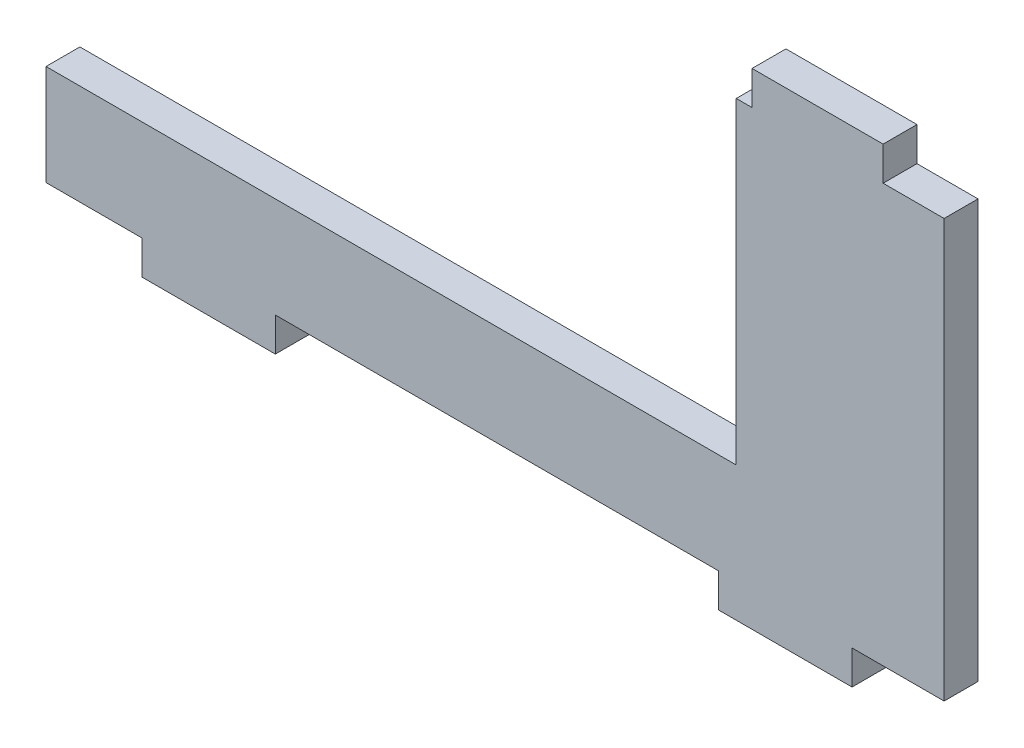
from build123d import *

# Parameters (mm, degrees)
SALIENTE_EXTRUIR1_DEPTH = 3


with BuildPart() as part:
    # Croquis1 → Saliente-Extruir1 (new body)
    with BuildSketch(Plane.XY):
        Polygon((21.35, -9.6), (-39.75, -9.6), (-39.75, -18.5), (-31.25, -18.5), (-31.25, -21.5), (-19.45, -21.5), (-19.45, -18.5), (19.8, -18.5), (19.8, -21.5), (31.6, -21.5), (31.6, -18.5), (39.75, -18.5), (39.75, 18.5), (34.35, 18.5), (34.35, 21.5), (22.75, 21.5), (22.75, 18.5), (21.35, 18.5), align=None)
    extrude(amount=SALIENTE_EXTRUIR1_DEPTH)


solid = part.part
